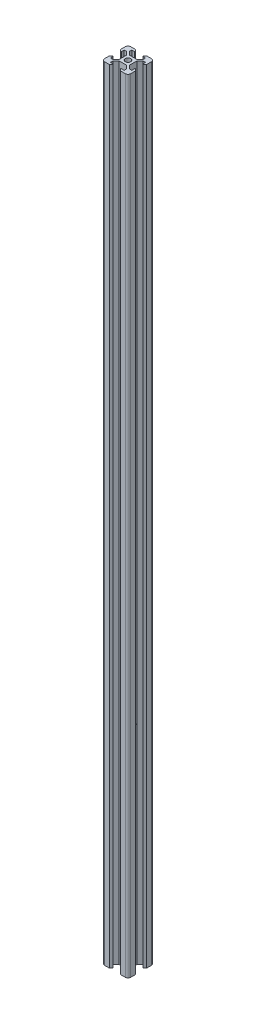
from build123d import *

# Parameters (mm, degrees)
CROQUIS1_R              = 2.1
SALIENTE_EXTRUIR2_DEPTH = 600
CROQUIS2_R              = 2.1
CORTAR_EXTRUIR2_DEPTH   = 175


with BuildPart() as part:
    # Croquis1 → Saliente-Extruir2 (new body)
    with BuildSketch(Plane(origin=(0, 0, 0), x_dir=(1, 0, 0), z_dir=(0, 1, 0))):
        with BuildLine():
            Line((3.9, -2.84), (3.9, 2.84))
            Line((3.9, 2.84), (6.36, 5.3))
            Line((6.36, 5.3), (8.2, 5.3))
            Line((8.2, 5.3), (8.2, 3.34))
            ThreePointArc((8.2, 3.34), (8.346446609, 2.986446609), (8.7, 2.84))
            Line((8.7, 2.84), (10, 4.14))
            Line((10, 4.14), (10, 8))
            ThreePointArc((10, 8), (9.414213562, 9.414213562), (8, 10))
            Line((8, 10), (4.14, 10))
            Line((4.14, 10), (2.84, 8.7))
            ThreePointArc((2.84, 8.7), (2.986446609, 8.346446609), (3.34, 8.2))
            Line((3.34, 8.2), (5.3, 8.2))
            Line((5.3, 8.2), (5.3, 6.36))
            Line((5.3, 6.36), (2.84, 3.9))
            Line((2.84, 3.9), (-2.84, 3.9))
            Line((-2.84, 3.9), (-5.3, 6.36))
            Line((-5.3, 6.36), (-5.3, 8.2))
            Line((-5.3, 8.2), (-3.34, 8.2))
            ThreePointArc((-3.34, 8.2), (-2.986446609, 8.346446609), (-2.84, 8.7))
            Line((-2.84, 8.7), (-4.14, 10))
            Line((-4.14, 10), (-8, 10))
            ThreePointArc((-8, 10), (-9.414213562, 9.414213562), (-10, 8))
            Line((-10, 8), (-10, 4.14))
            Line((-10, 4.14), (-8.7, 2.84))
            ThreePointArc((-8.7, 2.84), (-8.346446609, 2.986446609), (-8.2, 3.34))
            Line((-8.2, 3.34), (-8.2, 5.3))
            Line((-8.2, 5.3), (-6.36, 5.3))
            Line((-6.36, 5.3), (-3.9, 2.84))
            Line((-3.9, 2.84), (-3.9, -2.84))
            Line((-3.9, -2.84), (-6.36, -5.3))
            Line((-6.36, -5.3), (-8.2, -5.3))
            Line((-8.2, -5.3), (-8.2, -3.34))
            ThreePointArc((-8.2, -3.34), (-8.346446609, -2.986446609), (-8.7, -2.84))
            Line((-8.7, -2.84), (-10, -4.14))
            Line((-10, -4.14), (-10, -8))
            ThreePointArc((-10, -8), (-9.414213562, -9.414213562), (-8, -10))
            Line((-8, -10), (-4.14, -10))
            Line((-4.14, -10), (-2.84, -8.7))
            ThreePointArc((-2.84, -8.7), (-2.986446609, -8.346446609), (-3.34, -8.2))
            Line((-3.34, -8.2), (-5.3, -8.2))
            Line((-5.3, -8.2), (-5.3, -6.36))
            Line((-5.3, -6.36), (-2.84, -3.9))
            Line((-2.84, -3.9), (2.84, -3.9))
            Line((2.84, -3.9), (5.3, -6.36))
            Line((5.3, -6.36), (5.3, -8.2))
            Line((5.3, -8.2), (3.34, -8.2))
            ThreePointArc((3.34, -8.2), (2.986446609, -8.346446609), (2.84, -8.7))
            Line((2.84, -8.7), (4.14, -10))
            Line((4.14, -10), (8, -10))
            ThreePointArc((8, -10), (9.414213562, -9.414213562), (10, -8))
            Line((10, -8), (10, -4.14))
            Line((10, -4.14), (8.7, -2.84))
            ThreePointArc((8.7, -2.84), (8.346446609, -2.986446609), (8.2, -3.34))
            Line((8.2, -3.34), (8.2, -5.3))
            Line((8.2, -5.3), (6.36, -5.3))
            Line((6.36, -5.3), (3.9, -2.84))
        make_face()
        Circle(CROQUIS1_R, mode=Mode.SUBTRACT)
    extrude(amount=SALIENTE_EXTRUIR2_DEPTH)

    # Croquis2 → Cortar-Extruir2 (cut, symmetric)
    with BuildSketch(Plane(origin=(0, 0, 0), x_dir=(0, 0, -1), z_dir=(1, 0, 0))):
        with Locations((0, 160)):
            Circle(CROQUIS2_R)
    extrude(amount=CORTAR_EXTRUIR2_DEPTH, both=True, mode=Mode.SUBTRACT)


solid = part.part
